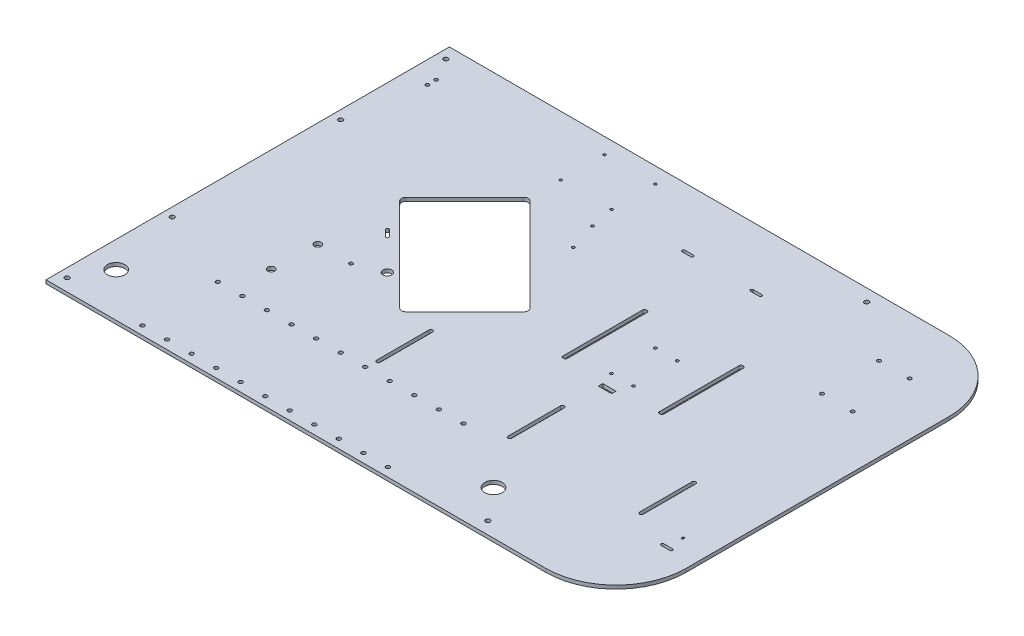
from build123d import *

# Parameters (mm, degrees)
SKETCH_1_W             = 650
SKETCH_1_H             = 460
EXTRUDE_1_DEPTH        = 4
SKETCH_3_R             = 2.05
CUT_EXTRUDE_2_DEPTH    = 5
CUT_EXTRUDE_1515_DEPTH = 5
SKETCH_5_R             = 2.6
CUT_EXTRUDE_2177_DEPTH = 5
FILLET_1_R             = 80
CUT_EXTRUDE_2788_DEPTH = 5
CUT_EXTRUDE_3372_DEPTH = 5
SKETCH_8_R             = 1.5
CUT_EXTRUDE_3986_DEPTH = 5
SKETCH_9_R             = 2.25
CUT_EXTRUDE_4689_DEPTH = 5
FILLET_2_R             = 80
SKETCH_10_R            = 1.6
SKETCH_10_W            = 5
SKETCH_10_H            = 95
CUT_EXTRUDE_5264_DEPTH = 5
FILLET_3_R             = 5
FILLET_4_R             = 2
SKETCH_11_W            = 2
SKETCH_11_H            = 3
CUT_EXTRUDE_6150_DEPTH = 5
CUT_EXTRUDE_6369_DEPTH = 5
SKETCH_13_W            = 15
SKETCH_13_H            = 5
CUT_EXTRUDE_6552_DEPTH = 5
SKETCH_15_R            = 2
SKETCH_15_R_2          = 4
CUT_EXTRUDE_6861_DEPTH = 5
SKETCH_16_R            = 5
SKETCH_16_R_2          = 10
SKETCH_16_R_3          = 4
CUT_EXTRUDE_12_DEPTH   = 5
SKETCH_17_R            = 2
CUT_EXTRUDE_13_DEPTH   = 5
SKETCH_18_R            = 1.6
CUT_EXTRUDE_14_DEPTH   = 5


with BuildPart() as part:
    # 草图1 → 凸台-拉伸1 (new body)
    with BuildSketch(Plane(origin=(0, 0, 0), x_dir=(1, 0, 0), z_dir=(0, 1, 0))):
        Rectangle(SKETCH_1_W, SKETCH_1_H)
    extrude(amount=EXTRUDE_1_DEPTH)

    # 草图3 → 切除-拉伸2 (cut, through all)
    with BuildSketch(Plane(origin=(0, 4, 0), x_dir=(1, 0, 0), z_dir=(0, 1, 0))):
        with Locations((230, 165)):
            Circle(SKETCH_3_R)
        with Locations((265, 165)):
            Circle(SKETCH_3_R)
        with Locations((265, 100)):
            Circle(SKETCH_3_R)
        with Locations((230, 100)):
            Circle(SKETCH_3_R)
    extrude(amount=-CUT_EXTRUDE_2_DEPTH, mode=Mode.SUBTRACT)

    # 草图4 → Cut-Extrude 1515 (cut, through all)
    with BuildSketch(Plane(origin=(0, 4, 0), x_dir=(1, 0, 0), z_dir=(0, 1, 0))):
        Polygon((-204.791847198, 53.223304703), (-130.545635174, 127.469516728), (-17.408550184, 14.332431738), (-91.654762208, -59.913780286), align=None)
    extrude(amount=-CUT_EXTRUDE_1515_DEPTH, mode=Mode.SUBTRACT)

    # 草图5 → Cut-Extrude 2177 (cut, through all)
    with BuildSketch(Plane(origin=(0, 4, 0), x_dir=(1, 0, 0), z_dir=(0, 1, 0))):
        with Locations((165, -216)):
            Circle(SKETCH_5_R)
        with Locations((-315, -216)):
            Circle(SKETCH_5_R)
        with Locations((-315, 216)):
            Circle(SKETCH_5_R)
        with Locations((165, 216)):
            Circle(SKETCH_5_R)
        with Locations((-315, 96)):
            Circle(SKETCH_5_R)
        with Locations((-315, -96)):
            Circle(SKETCH_5_R)
    extrude(amount=-CUT_EXTRUDE_2177_DEPTH, mode=Mode.SUBTRACT)

    # 圆角1
    fillet_1_edges = [part.edges().sort_by_distance(p)[0] for p in [
        (325, 2, -230),
    ]]
    fillet(fillet_1_edges, radius=FILLET_1_R)

    # 草图6 → Cut-Extrude 2788 (cut, through all)
    with BuildSketch(Plane(origin=(0, 4, 0), x_dir=(1, 0, 0), z_dir=(0, 1, 0))):
        with BuildLine():
            Line((10, 163.6), (20, 163.6))
            ThreePointArc((20, 163.6), (21.6, 162), (20, 160.4))
            Line((20, 160.4), (10, 160.4))
            ThreePointArc((10, 160.4), (8.4, 162), (10, 163.6))
        make_face()
        with BuildLine():
            Line((88, 163.6), (98, 163.6))
            ThreePointArc((98, 163.6), (99.6, 162), (98, 160.4))
            Line((98, 160.4), (88, 160.4))
            ThreePointArc((88, 160.4), (86.4, 162), (88, 163.6))
        make_face()
    extrude(amount=-CUT_EXTRUDE_2788_DEPTH, mode=Mode.SUBTRACT)

    # 草图7 → Cut-Extrude 3372 (cut, through all)
    with BuildSketch(Plane(origin=(0, 4, 0), x_dir=(1, 0, 0), z_dir=(0, 1, 0))):
        with BuildLine():
            Line((247.1, -61), (247.1, -121))
            ThreePointArc((247.1, -121), (245, -123.1), (242.9, -121))
            Line((242.9, -121), (242.9, -61))
            ThreePointArc((242.9, -61), (245, -58.9), (247.1, -61))
        make_face()
        with BuildLine():
            Line((97.1, -61), (97.1, -121))
            ThreePointArc((97.1, -121), (95, -123.1), (92.9, -121))
            Line((92.9, -121), (92.9, -61))
            ThreePointArc((92.9, -61), (95, -58.9), (97.1, -61))
        make_face()
        with BuildLine():
            Line((-52.9, -61), (-52.9, -121))
            ThreePointArc((-52.9, -121), (-55, -123.1), (-57.1, -121))
            Line((-57.1, -121), (-57.1, -61))
            ThreePointArc((-57.1, -61), (-55, -58.9), (-52.9, -61))
        make_face()
    extrude(amount=-CUT_EXTRUDE_3372_DEPTH, mode=Mode.SUBTRACT)

    # 草图8 → Cut-Extrude 3986 (cut, through all)
    with BuildSketch(Plane(origin=(0, 4, 0), x_dir=(1, 0, 0), z_dir=(0, 1, 0))):
        with Locations((-130, 212)):
            Circle(SKETCH_8_R)
        with Locations((-72, 212)):
            Circle(SKETCH_8_R)
        with Locations((-72, 162)):
            Circle(SKETCH_8_R)
        with Locations((-130, 162)):
            Circle(SKETCH_8_R)
    extrude(amount=-CUT_EXTRUDE_3986_DEPTH, mode=Mode.SUBTRACT)

    # 草图9 → Cut-Extrude 4689 (cut, through all)
    with BuildSketch(Plane(origin=(0, 4, 0), x_dir=(1, 0, 0), z_dir=(0, 1, 0))):
        with Locations((-225, -220)):
            Circle(SKETCH_9_R)
        with Locations((-197, -220)):
            Circle(SKETCH_9_R)
        with Locations((-169, -220)):
            Circle(SKETCH_9_R)
        with Locations((-141, -220)):
            Circle(SKETCH_9_R)
        with Locations((-113, -220)):
            Circle(SKETCH_9_R)
        with Locations((-85, -220)):
            Circle(SKETCH_9_R)
        with Locations((-57, -220)):
            Circle(SKETCH_9_R)
        with Locations((-29, -220)):
            Circle(SKETCH_9_R)
        with Locations((-1, -220)):
            Circle(SKETCH_9_R)
        with Locations((27, -220)):
            Circle(SKETCH_9_R)
        with Locations((55, -220)):
            Circle(SKETCH_9_R)
        with Locations((-197, -134)):
            Circle(SKETCH_9_R)
        with Locations((-169, -134)):
            Circle(SKETCH_9_R)
        with Locations((-141, -134)):
            Circle(SKETCH_9_R)
        with Locations((-113, -134)):
            Circle(SKETCH_9_R)
        with Locations((-85, -134)):
            Circle(SKETCH_9_R)
        with Locations((-57, -134)):
            Circle(SKETCH_9_R)
        with Locations((-29, -134)):
            Circle(SKETCH_9_R)
        with Locations((-1, -134)):
            Circle(SKETCH_9_R)
        with Locations((27, -134)):
            Circle(SKETCH_9_R)
        with Locations((55, -134)):
            Circle(SKETCH_9_R)
        with Locations((-225, -134)):
            Circle(SKETCH_9_R)
    extrude(amount=-CUT_EXTRUDE_4689_DEPTH, mode=Mode.SUBTRACT)

    # 圆角2
    fillet_2_edges = [part.edges().sort_by_distance(p)[0] for p in [
        (325, 2, 230),
    ]]
    fillet(fillet_2_edges, radius=FILLET_2_R)

    # 草图10 → Cut-Extrude 5264 (cut, through all)
    with BuildSketch(Plane(origin=(0, 4, 0), x_dir=(1, 0, 0), z_dir=(0, 1, 0))):
        with Locations((115, 50)):
            Circle(SKETCH_10_R)
        with Locations((115, 0)):
            Circle(SKETCH_10_R)
        with Locations((90, 0)):
            Circle(SKETCH_10_R)
        with Locations((90, 50)):
            Circle(SKETCH_10_R)
        with Locations((47.5, 35)):
            Rectangle(SKETCH_10_W, SKETCH_10_H)
        with Locations((157.5, 35)):
            Rectangle(SKETCH_10_W, SKETCH_10_H)
    extrude(amount=-CUT_EXTRUDE_5264_DEPTH, mode=Mode.SUBTRACT)

    # 圆角3
    fillet_3_edges = [part.edges().sort_by_distance(p)[0] for p in [
        (-91.654762208, 2, 59.913780286),
        (-204.791847198, 2, -53.223304703),
        (-130.545635174, 2, -127.469516728),
        (-17.408550184, 2, -14.332431738),
    ]]
    fillet(fillet_3_edges, radius=FILLET_3_R)

    # 圆角4
    fillet_4_edges = [part.edges().sort_by_distance(p)[0] for p in [
        (155, 2, 12.5),
        (155, 2, -82.5),
        (160, 2, -82.5),
        (160, 2, 12.5),
        (50, 2, -82.5),
        (50, 2, 12.5),
        (45, 2, 12.5),
        (45, 2, -82.5),
    ]]
    fillet(fillet_4_edges, radius=FILLET_4_R)

    # 草图11 → Cut-Extrude 6150 (cut, through all)
    with BuildSketch(Plane(origin=(0, 4, 0), x_dir=(1, 0, 0), z_dir=(0, 1, 0))):
        with BuildLine():
            Line((288, -138.4), (298, -138.4))
            ThreePointArc((298, -138.4), (299.6, -140), (298, -141.6))
            Line((298, -141.6), (288, -141.6))
            ThreePointArc((288, -141.6), (286.4, -140), (288, -138.4))
        make_face()
        with Locations((293.262535805, -122)):
            Rectangle(SKETCH_11_W, SKETCH_11_H)
    extrude(amount=-CUT_EXTRUDE_6150_DEPTH, mode=Mode.SUBTRACT)

    # 草图12 → Cut-Extrude 6369 (cut, through all)
    with BuildSketch(Plane(origin=(0, 4, 0), x_dir=(1, 0, 0), z_dir=(0, 1, 0))):
        with BuildLine():
            Line((-178.911739007, 15.463802588), (-171.840671195, 8.392734776))
            ThreePointArc((-171.840671195, 8.392734776), (-171.840671195, 6.129993076), (-174.103412895, 6.129993076))
            Line((-174.103412895, 6.129993076), (-181.174480707, 13.201060888))
            ThreePointArc((-181.174480707, 13.201060888), (-181.174480707, 15.463802588), (-178.911739007, 15.463802588))
        make_face()
    extrude(amount=-CUT_EXTRUDE_6369_DEPTH, mode=Mode.SUBTRACT)

    # 草图13 → Cut-Extrude 6552 (cut, through all)
    with BuildSketch(Plane(origin=(0, 4, 0), x_dir=(1, 0, 0), z_dir=(0, 1, 0))):
        with Locations((102.5, -17.5)):
            Rectangle(SKETCH_13_W, SKETCH_13_H)
    extrude(amount=-CUT_EXTRUDE_6552_DEPTH, mode=Mode.SUBTRACT)

    # 草图15 → Cut-Extrude 6861 (cut, through all)
    with BuildSketch(Plane(origin=(0, 4, 0), x_dir=(1, 0, 0), z_dir=(0, 1, 0))):
        with Locations((-167, -40)):
            Circle(SKETCH_15_R)
        with Locations((-205, -40)):
            Circle(SKETCH_15_R_2)
    extrude(amount=-CUT_EXTRUDE_6861_DEPTH, mode=Mode.SUBTRACT)

    # 草图16 → 切除-拉伸12 (cut, through all)
    with BuildSketch(Plane(origin=(0, 4, 0), x_dir=(1, 0, 0), z_dir=(0, 1, 0))):
        with Locations((-137.616702986, -28.093975133)):
            Circle(SKETCH_16_R)
        with Locations((-295, -180)):
            Circle(SKETCH_16_R_2)
        with Locations((135.386397476, -180)):
            Circle(SKETCH_16_R_2)
        with Locations((-207.1, -91)):
            Circle(SKETCH_16_R_3)
    extrude(amount=-CUT_EXTRUDE_12_DEPTH, mode=Mode.SUBTRACT)

    # 草图17 → 切除-拉伸13 (cut, through all)
    with BuildSketch(Plane(origin=(0, 4, 0), x_dir=(1, 0, 0), z_dir=(0, 1, 0))):
        with Locations((-300, 190)):
            Circle(SKETCH_17_R)
        with Locations((-300, 180)):
            Circle(SKETCH_17_R)
    extrude(amount=-CUT_EXTRUDE_13_DEPTH, mode=Mode.SUBTRACT)

    # 草图18 → 切除-拉伸14 (cut, through all)
    with BuildSketch(Plane(origin=(0, 4, 0), x_dir=(1, 0, 0), z_dir=(0, 1, 0))):
        with Locations((-66.552471476, 134.89413793)):
            Circle(SKETCH_18_R)
        with Locations((-56.299423149, 102.720779386)):
            Circle(SKETCH_18_R)
    extrude(amount=-CUT_EXTRUDE_14_DEPTH, mode=Mode.SUBTRACT)


solid = part.part
